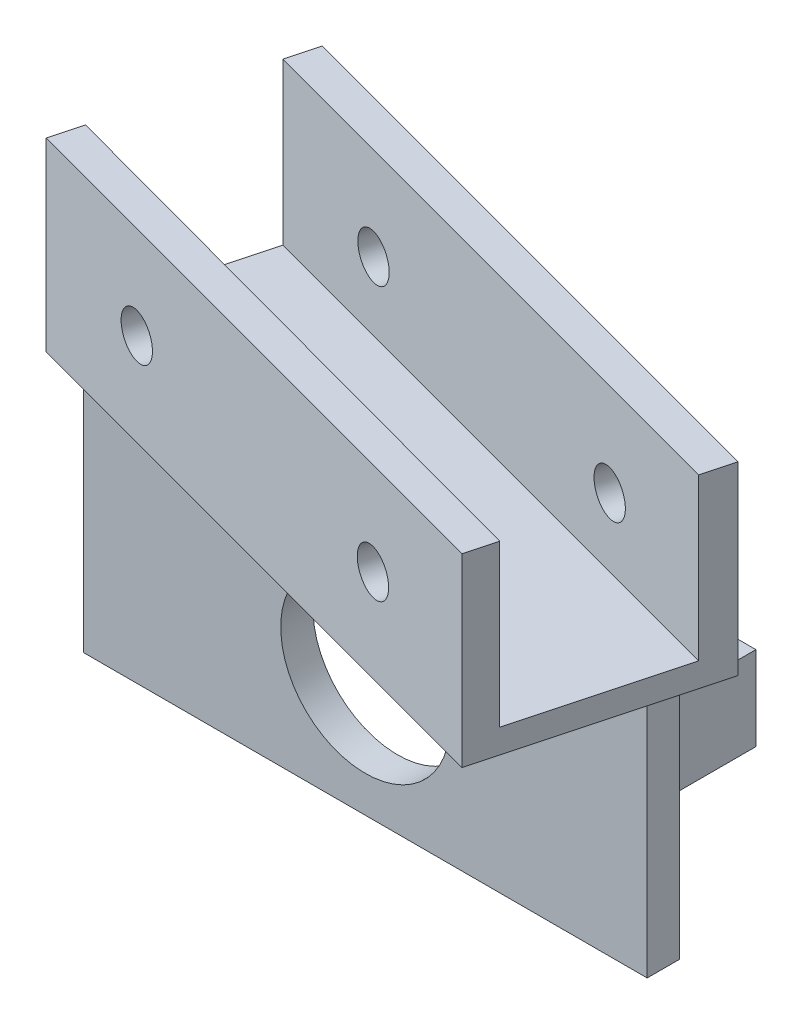
from build123d import *

# Parameters (mm, degrees)
SKETCH1_W           = 70
SKETCH1_H           = 30
SKETCH1_R           = 10.5
BOSS_EXTRUDE1_DEPTH = 4
SKETCH3_W           = 8.150987667
SKETCH3_H           = 10.43538234
SKETCH3_W_2         = 6.820916115
SKETCH3_H_2         = 20
BOSS_EXTRUDE2_DEPTH = 17
SKETCH4_R           = 1
CUT_EXTRUDE1_DEPTH  = 17
BOSS_EXTRUDE4_DEPTH = 3
BOSS_EXTRUDE5_DEPTH = 20
SKETCH10_R          = 2.75
CUT_EXTRUDE2_DEPTH  = 47.25


with BuildPart() as part:
    # Sketch1 → Boss-Extrude1 (new body)
    with BuildSketch(Plane.XY):
        with Locations((35, -15)):
            Rectangle(SKETCH1_W, SKETCH1_H)
        with Locations((35, -15)):
            Circle(SKETCH1_R, mode=Mode.SUBTRACT)
    extrude(amount=BOSS_EXTRUDE1_DEPTH)

    # Sketch3 → Boss-Extrude2 (add)
    with BuildSketch(Plane(origin=(0, 0, 0), x_dir=(-1, 0, 0), z_dir=(0, 0, -1))):
        with Locations((-58.424506167, -14.156074174)):
            Rectangle(SKETCH3_W, SKETCH3_H)
        with Locations((-10.910458058, -15)):
            Rectangle(SKETCH3_W_2, SKETCH3_H_2)
    extrude(amount=BOSS_EXTRUDE2_DEPTH)

    # Sketch4 → Cut-Extrude1 (cut)
    with BuildSketch(Plane(origin=(0, 0, -17), x_dir=(-1, 0, 0), z_dir=(0, 0, -1))):
        with Locations((-58.5, -14.289099526)):
            Circle(SKETCH4_R)
        with Locations((-11.5, -7)):
            Circle(SKETCH4_R)
        with Locations((-11.5, -23)):
            Circle(SKETCH4_R)
    extrude(amount=-CUT_EXTRUDE1_DEPTH, mode=Mode.SUBTRACT)

    # Sketch7 → Boss-Extrude4 (add)
    with BuildSketch(Plane(origin=(0, 0, 0), x_dir=(1, 0, 0), z_dir=(0, 1, 0))):
        Polygon((-4.630368757, -4), (65.882216562, -22.893790292), (73.129149825, 4.152132844), (2.616564506, 23.045923136), align=None)
    extrude(amount=BOSS_EXTRUDE4_DEPTH)

    # Sketch9 → Boss-Extrude5 (add)
    with BuildSketch(Plane(origin=(0, 3, 0), x_dir=(1, 0, 0), z_dir=(0, 1, 0))):
        Polygon((-4.630368757, -4), (65.882216562, -22.893790292), (66.875377983, -19.18726141), (-3.595092577, -0.136296695), align=None)
        Polygon((2.616564506, 23.045923136), (1.581288325, 19.182219831), (72.093873644, 0.288429538), (73.129149825, 4.152132844), align=None)
    extrude(amount=BOSS_EXTRUDE5_DEPTH)

    # Sketch10 → Cut-Extrude2 (cut, through all)
    with BuildSketch(Plane(origin=(5.936757371, 0, -22.156280139), x_dir=(-0.965925826, 0, -0.258819045), z_dir=(0.258819045, 0, -0.965925826))):
        with Locations((-53.953749554, 11.5)):
            Circle(SKETCH10_R)
        with Locations((-12.488324975, 11.5)):
            Circle(SKETCH10_R)
    extrude(amount=-CUT_EXTRUDE2_DEPTH, mode=Mode.SUBTRACT)


solid = part.part
